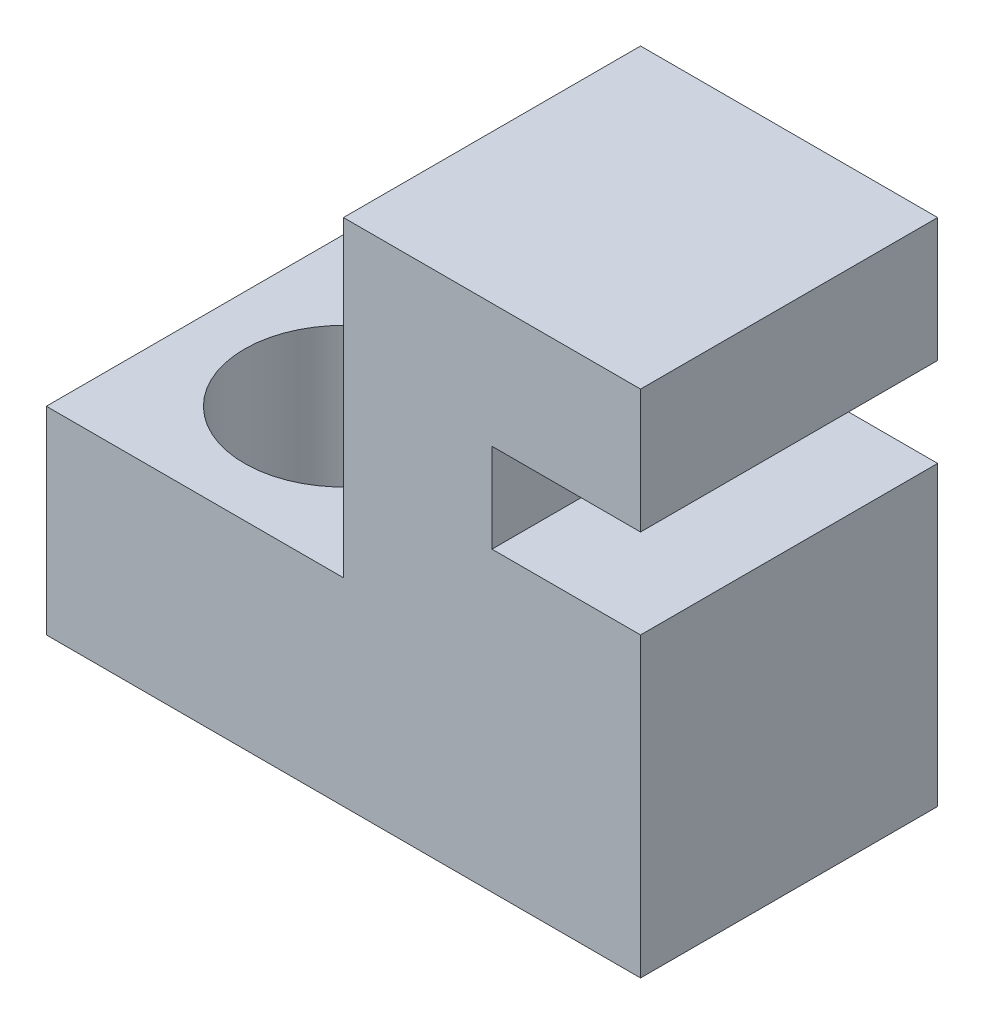
from build123d import *

# Parameters (mm, degrees)
EXTRUDE_1_DEPTH     = 6
SKETCH_2_R          = 2
CUT_EXTRUDE_1_DEPTH = 5


with BuildPart() as part:
    # Эскиз1 → Бобышка-Вытянуть1 (new body)
    with BuildSketch(Plane.XY):
        Polygon((0, 0), (0, 4), (6, 4), (6, 10.3), (12, 10.3), (12, 7.8), (9, 7.8), (9, 6), (12, 6), (12, 0), align=None)
    extrude(amount=EXTRUDE_1_DEPTH)

    # Эскиз2 → Вырез-Вытянуть1 (cut, through all)
    with BuildSketch(Plane(origin=(0, 4, 0), x_dir=(1, 0, 0), z_dir=(0, 1, 0))):
        with Locations((3, -3)):
            Circle(SKETCH_2_R)
    extrude(amount=-CUT_EXTRUDE_1_DEPTH, mode=Mode.SUBTRACT)


solid = part.part
